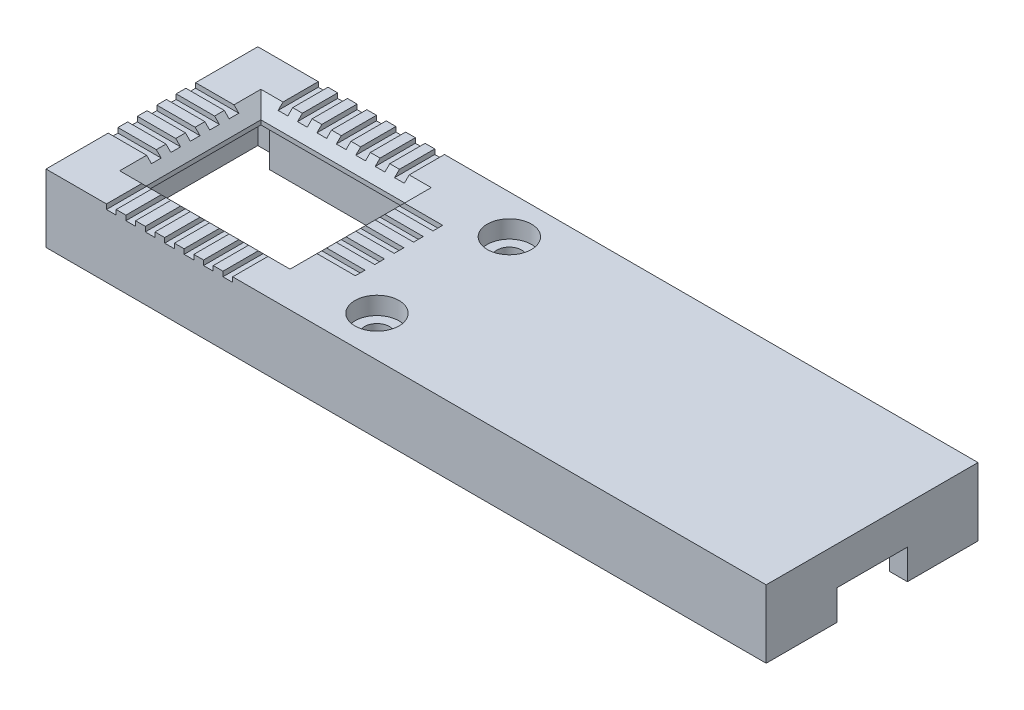
from build123d import *

# Parameters (mm, degrees)
SKETCH2_W           = 81.6
SKETCH2_H           = 24
SKETCH2_W_2         = 77.6
SKETCH2_H_2         = 20
BOSS_EXTRUDE1_DEPTH = 7.7
SKETCH3_W           = 77.6
SKETCH3_H           = 20
BOSS_EXTRUDE2_DEPTH = 2
SKETCH4_W           = 16.3
SKETCH4_H           = 13
CUT_EXTRUDE1_DEPTH  = 8.7
CUT_EXTRUDE2_REACH  = 83.6
SKETCH5_W           = 8
SKETCH5_H           = 6.8
SKETCH6_W           = 16.3
SKETCH6_H           = 2.5
SKETCH6_W_2         = 5
BOSS_EXTRUDE3_DEPTH = 4.9
SKETCH8_R           = 2.5
CUT_EXTRUDE3_DEPTH  = 2
SKETCH9_R           = 1.4
BOSS_EXTRUDE4_DEPTH = 2
SKETCH10_R          = 1.4
BOSS_EXTRUDE5_DEPTH = 2.9
CHAMFER1_SIZE       = 1.5
SKETCH11_W          = 1.1
SKETCH11_H          = 1.1
CUT_EXTRUDE4_DEPTH  = 25
LPATTERN1_COUNT     = 4
LPATTERN1_PITCH     = 2.2
LPATTERN2_COUNT     = 4
LPATTERN2_PITCH     = 2.2
SKETCH12_W          = 1.1
SKETCH12_H          = 1.1
CUT_EXTRUDE5_DEPTH  = 28
LPATTERN3_COUNT     = 3
LPATTERN3_PITCH     = 2.2
LPATTERN4_COUNT     = 3
LPATTERN4_PITCH     = 2.2


with BuildPart() as part:
    # Sketch2 → Boss-Extrude1 (new body)
    with BuildSketch(Plane(origin=(0, 0, 0), x_dir=(1, 0, 0), z_dir=(0, 1, 0))):
        Rectangle(SKETCH2_W, SKETCH2_H)
        Rectangle(SKETCH2_W_2, SKETCH2_H_2, mode=Mode.SUBTRACT)
    extrude(amount=BOSS_EXTRUDE1_DEPTH)

    # Sketch3 → Boss-Extrude2 (add)
    with BuildSketch(Plane(origin=(0, 7.7, 0), x_dir=(1, 0, 0), z_dir=(0, 1, 0))):
        Rectangle(SKETCH3_W, SKETCH3_H)
    extrude(amount=-BOSS_EXTRUDE2_DEPTH)

    # Sketch4 → Cut-Extrude1 (cut, through all)
    with BuildSketch(Plane(origin=(0, 7.7, 0), x_dir=(1, 0, 0), z_dir=(0, 1, 0))):
        with Locations((-26.8, 0)):
            Rectangle(SKETCH4_W, SKETCH4_H)
    extrude(amount=-CUT_EXTRUDE1_DEPTH, mode=Mode.SUBTRACT)

    # Sketch5 → Cut-Extrude2 (cut, up to next)
    with BuildSketch(Plane(origin=(40.8, 0, 0), x_dir=(0, 0, -1), z_dir=(1, 0, 0)), mode=Mode.PRIVATE) as cut_extrude2_sk1:
        Rectangle(SKETCH5_W, SKETCH5_H)
    cut_extrude2_tool1 = extrude(cut_extrude2_sk1.sketch, amount=-CUT_EXTRUDE2_REACH, mode=Mode.PRIVATE) & part.part
    add(cut_extrude2_tool1.solids().sort_by_distance((40.8, 0, 0))[0], mode=Mode.SUBTRACT)

    # Sketch6 → Boss-Extrude3 (add)
    with BuildSketch(Plane.XZ.offset(-5.7)):
        with Locations((-26.8, 8.75)):
            Rectangle(SKETCH6_W, SKETCH6_H)
        with Locations((-26.8, -8.75)):
            Rectangle(SKETCH6_W, SKETCH6_H)
        with Locations((30.65, 8.75)):
            Rectangle(SKETCH6_W, SKETCH6_H)
        with Locations((36.3, -8.75)):
            Rectangle(SKETCH6_W_2, SKETCH6_H)
    extrude(amount=BOSS_EXTRUDE3_DEPTH)

    # Sketch8 → Cut-Extrude3 (cut)
    with BuildSketch(Plane(origin=(0, 7.7, 0), x_dir=(1, 0, 0), z_dir=(0, 1, 0))):
        with Locations((-7.9, 7.6)):
            Circle(SKETCH8_R)
        with Locations((-7.9, -7.4)):
            Circle(SKETCH8_R)
    extrude(amount=-CUT_EXTRUDE3_DEPTH, mode=Mode.SUBTRACT)

    # Sketch9 → Boss-Extrude4 (add)
    with BuildSketch(Plane.XZ.offset(-5.7)):
        Polygon((-4.15, 4.8), (-4.15, 10), (-11.65, 10), (-11.65, 4.8), (-11.65, -5.2), (-11.65, -10), (-4.15, -10), (-4.15, -5.2), align=None)
        with Locations((-7.9, 7.4)):
            Circle(SKETCH9_R, mode=Mode.SUBTRACT)
        with Locations((-7.9, -7.6)):
            Circle(SKETCH9_R, mode=Mode.SUBTRACT)
    extrude(amount=BOSS_EXTRUDE4_DEPTH)

    # Sketch10 → Boss-Extrude5 (add)
    with BuildSketch(Plane.XZ.offset(-3.7)):
        with BuildLine():
            Line((-10.3, 7.4), (-10.3, 10))
            Line((-10.3, 10), (-5.5, 10))
            Line((-5.5, 10), (-5.5, 7.4))
            ThreePointArc((-5.5, 7.4), (-7.9, 5), (-10.3, 7.4))
        make_face()
        with Locations((-7.9, 7.4)):
            Circle(SKETCH10_R, mode=Mode.SUBTRACT)
        with BuildLine():
            Line((-10.3, -7.6), (-10.3, -10))
            Line((-10.3, -10), (-5.5, -10))
            Line((-5.5, -10), (-5.5, -7.6))
            ThreePointArc((-5.5, -7.6), (-7.9, -5.2), (-10.3, -7.6))
        make_face()
        with Locations((-7.9, -7.6)):
            Circle(SKETCH10_R, mode=Mode.SUBTRACT)
    extrude(amount=BOSS_EXTRUDE5_DEPTH)

    # Chamfer1
    chamfer1_edges = [part.edges().sort_by_distance(p)[0] for p in [
        (-18.65, 7.7, 0),
        (-26.8, 7.7, -6.5),
        (-34.95, 7.7, 0),
        (-26.8, 7.7, 6.5),
    ]]
    chamfer(chamfer1_edges, length=CHAMFER1_SIZE)

    # Sketch11 → Cut-Extrude4 (cut, through all)
    with BuildSketch(Plane.XY.offset(12)):
        with Locations((-26.8, 7.7)):
            Rectangle(SKETCH11_W, SKETCH11_H)
    cut_extrude4 = extrude(amount=-CUT_EXTRUDE4_DEPTH, mode=Mode.SUBTRACT)

    # LPattern1: Cut-Extrude4 ×4
    with Locations(*[(i * LPATTERN1_PITCH, 0, 0) for i in range(1, LPATTERN1_COUNT)]):
        add(cut_extrude4, mode=Mode.SUBTRACT)

    # LPattern2: Cut-Extrude4 ×4
    with Locations(*[(-i * LPATTERN2_PITCH, 0, 0) for i in range(1, LPATTERN2_COUNT)]):
        add(cut_extrude4, mode=Mode.SUBTRACT)

    # Sketch12 → Cut-Extrude5 (cut)
    with BuildSketch(Plane.ZY.offset(40.8)):
        with Locations((0, 7.7)):
            Rectangle(SKETCH12_W, SKETCH12_H)
    cut_extrude5 = extrude(amount=-CUT_EXTRUDE5_DEPTH, mode=Mode.SUBTRACT)

    # LPattern3: Cut-Extrude5 ×3
    with Locations(*[(0, 0, i * LPATTERN3_PITCH) for i in range(1, LPATTERN3_COUNT)]):
        add(cut_extrude5, mode=Mode.SUBTRACT)

    # LPattern4: Cut-Extrude5 ×3
    with Locations(*[(0, 0, -i * LPATTERN4_PITCH) for i in range(1, LPATTERN4_COUNT)]):
        add(cut_extrude5, mode=Mode.SUBTRACT)


solid = part.part
